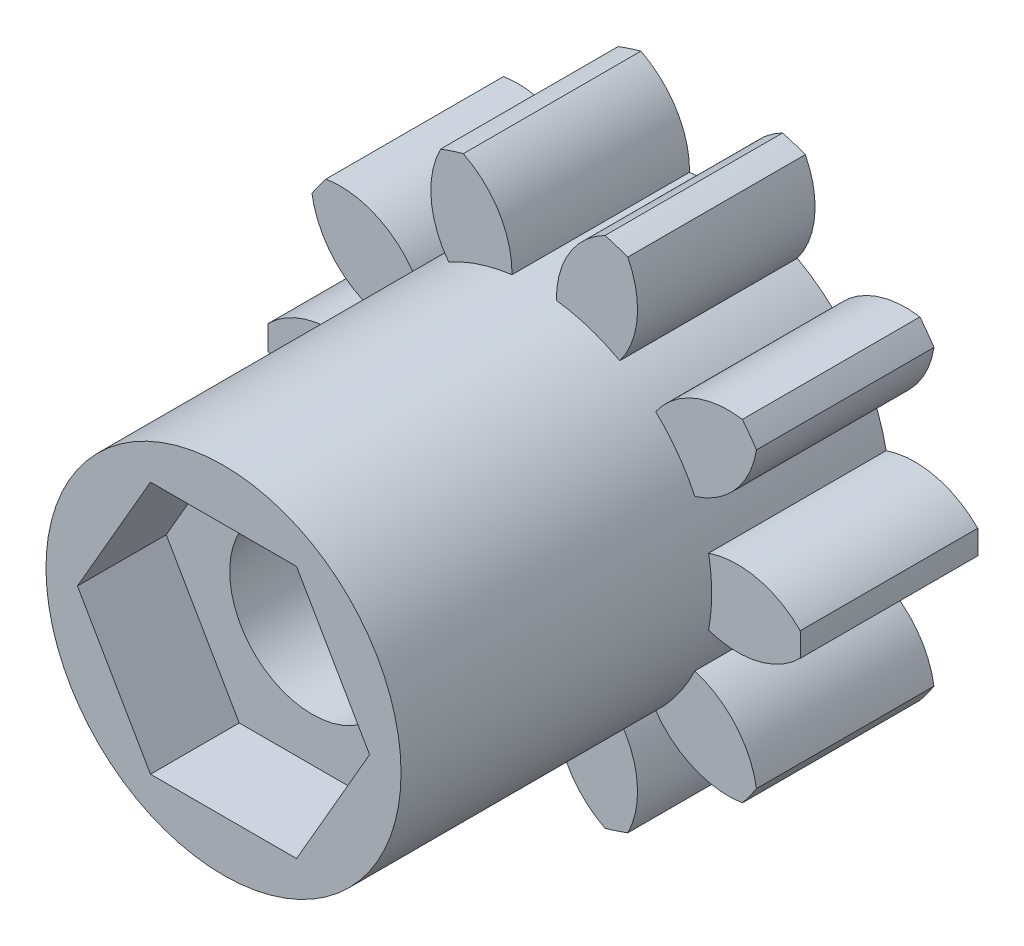
from build123d import *

# Parameters (mm, degrees)
SKETCH1_R           = 6
SKETCH1_R_2         = 2
BOSS_EXTRUDE1_DEPTH = 4
CUT_EXTRUDE2_DEPTH  = 10.38083152
CIRPATTERN2_COUNT   = 10
SKETCH11_R          = 4
BOSS_EXTRUDE2_DEPTH = 11
CUT_EXTRUDE3_START  = 11
CUT_EXTRUDE3_DEPTH  = 2
CUT_EXTRUDE4_DEPTH  = 14.800492389


with BuildPart() as part:
    # Sketch1 → Boss-Extrude1 (new body)
    with BuildSketch(Plane.XY):
        Circle(SKETCH1_R)
        Circle(SKETCH1_R_2, mode=Mode.SUBTRACT)
    extrude(amount=BOSS_EXTRUDE1_DEPTH)

    # Sketch4 → Cut-Extrude2 (cut, through all)
    with BuildSketch(Plane.XY):
        with BuildLine():
            ThreePointArc((-0.50024657, 3.968595894), (0, 4), (0.50024657, 3.968595894))
            ThreePointArc((0.50024657, 3.968595894), (1.074726656, 5.403066604), (2.5, 6))
            ThreePointArc((2.5, 6), (0, 6.5), (-2.5, 6))
            ThreePointArc((-2.5, 6), (-1.085786438, 5.414213562), (-0.5, 4))
            ThreePointArc((-0.5, 4), (-0.500061643, 3.984297463), (-0.50024657, 3.968595894))
        make_face()
    cut_extrude2 = extrude(amount=CUT_EXTRUDE2_DEPTH, mode=Mode.SUBTRACT)

    # CirPattern2: Cut-Extrude2 ×10 about axis
    cirpattern2_axis = Axis((0, 0, 4), (0, 0, -1))
    for i in range(1, CIRPATTERN2_COUNT):
        add(cut_extrude2.rotate(cirpattern2_axis, i * 360 / CIRPATTERN2_COUNT), mode=Mode.SUBTRACT)

    # Sketch11 → Boss-Extrude2 (add)
    with BuildSketch(Plane.XY):
        Circle(SKETCH11_R)
    extrude(amount=BOSS_EXTRUDE2_DEPTH)

    # Sketch12 → Cut-Extrude3 (cut)
    with BuildSketch(Plane.XY.offset(CUT_EXTRUDE3_START)):
        Polygon((3.290896534, 0), (1.645448267, 2.85), (-1.645448267, 2.85), (-3.290896534, 0), (-1.645448267, -2.85), (1.645448267, -2.85), align=None)
    extrude(amount=-CUT_EXTRUDE3_DEPTH, mode=Mode.SUBTRACT)

    # Sketch13 → Cut-Extrude4 (cut, through all)
    with BuildSketch(Plane.XY):
        with BuildLine():
            ThreePointArc((-1.6, 0.95), (0, -1.860779407), (1.6, 0.95))
            Line((1.6, 0.95), (-1.6, 0.95))
        make_face()
    extrude(amount=CUT_EXTRUDE4_DEPTH, mode=Mode.SUBTRACT)


solid = part.part
